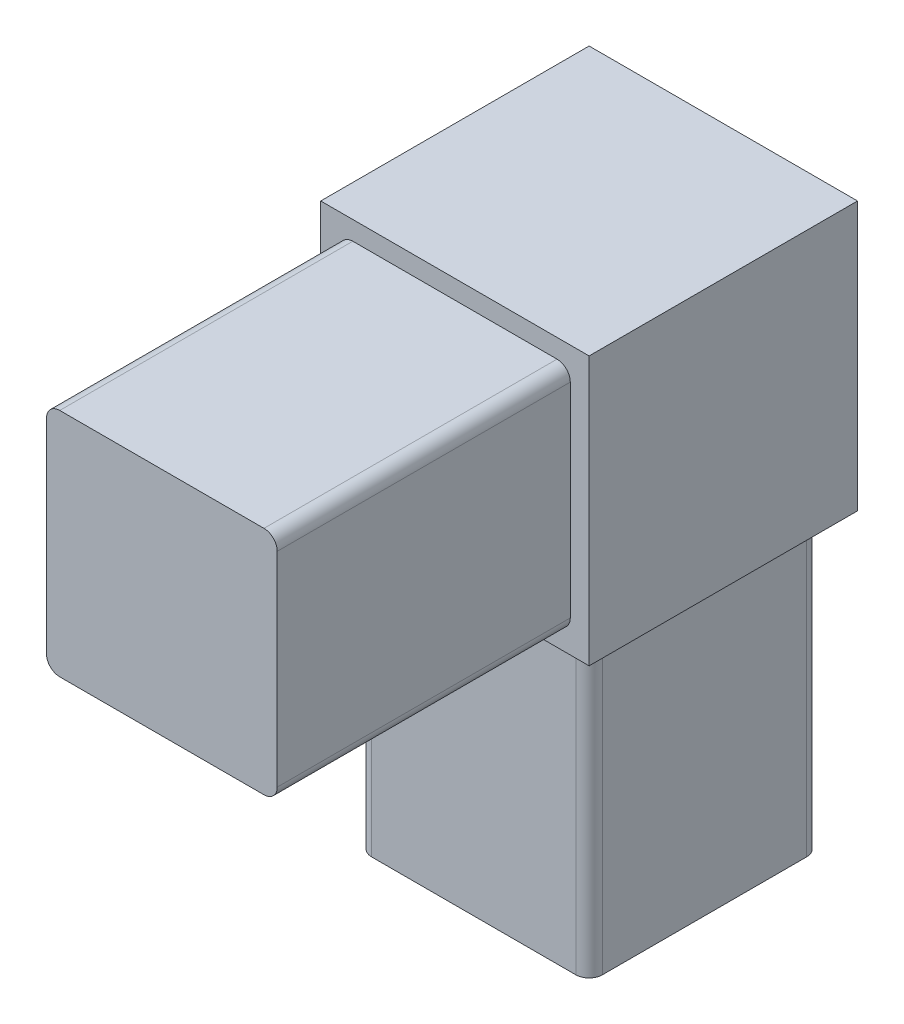
from build123d import *

# Parameters (mm, degrees)
SKETCH1_W           = 22.098
SKETCH1_H           = 22.098
BOSS_EXTRUDE1_DEPTH = 28.067
SKETCH2_W           = 25.7048
SKETCH2_H           = 25.7048
BOSS_EXTRUDE2_DEPTH = 25.7048
SKETCH3_W           = 22.098
SKETCH3_H           = 22.098
BOSS_EXTRUDE3_DEPTH = 28.067
FILLET1_R           = 1.27


with BuildPart() as part:
    # Sketch1 → Boss-Extrude1 (new body)
    with BuildSketch(Plane(origin=(0, 0, 0), x_dir=(1, 0, 0), z_dir=(0, 1, 0))):
        Rectangle(SKETCH1_W, SKETCH1_H)
    extrude(amount=BOSS_EXTRUDE1_DEPTH)

    # Sketch2 → Boss-Extrude2 (add)
    with BuildSketch(Plane(origin=(0, 28.067, 0), x_dir=(1, 0, 0), z_dir=(0, 1, 0))):
        Rectangle(SKETCH2_W, SKETCH2_H)
    extrude(amount=BOSS_EXTRUDE2_DEPTH)

    # Sketch3 → Boss-Extrude3 (add)
    with BuildSketch(Plane.XY.offset(12.8524)):
        with Locations((0, 40.9194)):
            Rectangle(SKETCH3_W, SKETCH3_H)
    extrude(amount=BOSS_EXTRUDE3_DEPTH)

    # Fillet1
    fillet1_edges = [part.edges().sort_by_distance(p)[0] for p in [
        (11.049, 29.8704, 26.8859),
        (11.049, 51.9684, 26.8859),
        (-11.049, 51.9684, 26.8859),
        (-11.049, 29.8704, 26.8859),
        (11.049, 14.0335, 11.049),
        (-11.049, 14.0335, 11.049),
        (-11.049, 14.0335, -11.049),
        (11.049, 14.0335, -11.049),
    ]]
    fillet(fillet1_edges, radius=FILLET1_R)


solid = part.part
